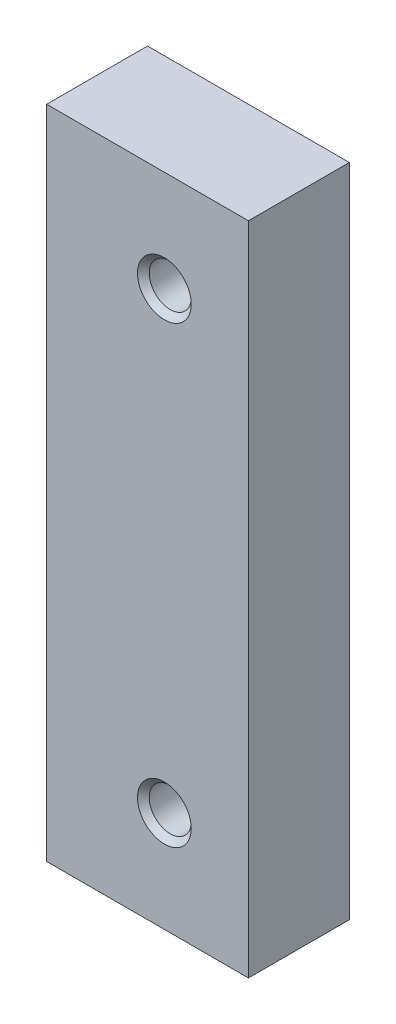
from build123d import *

# Parameters (mm, degrees)
SKETCH_1_W                 = 12
SKETCH_1_H                 = 6
EXTRUDE_1_DEPTH            = 39
HOLE_WIZARD_M31_AT_2_COUNT = 2
HOLE_WIZARD_M31_AT_2_PITCH = 27


with BuildPart() as part:
    # Эскиз1 → Бобышка-Вытянуть1 (new body)
    with BuildSketch(Plane(origin=(0, 0, 0), x_dir=(1, 0, 0), z_dir=(0, 1, 0))):
        with Locations((6, 3)):
            Rectangle(SKETCH_1_W, SKETCH_1_H)
    extrude(amount=EXTRUDE_1_DEPTH)

    # Эскиз2 → Отверстие обработанное метчиком M31 (revolve, cut)
    with BuildSketch(Plane(origin=(7, 6, 0), x_dir=(0, -1, 0), z_dir=(1, 0, 0))):
        Polygon((0, 0), (0, 6), (1.6, 6), (1.25, 5.65), (1.25, 0.35), (1.6, 0), align=None)
    hole_wizard_m31 = revolve(axis=Axis((7, 6, 6.35), (0, 0, -1)), mode=Mode.SUBTRACT)

    # Отверстие обработанное метчиком M31 at 2: Отверстие обработанное метчиком M31 ×2
    with Locations(*[(0, i * HOLE_WIZARD_M31_AT_2_PITCH, 0) for i in range(1, HOLE_WIZARD_M31_AT_2_COUNT)]):
        add(hole_wizard_m31, mode=Mode.SUBTRACT)


solid = part.part
